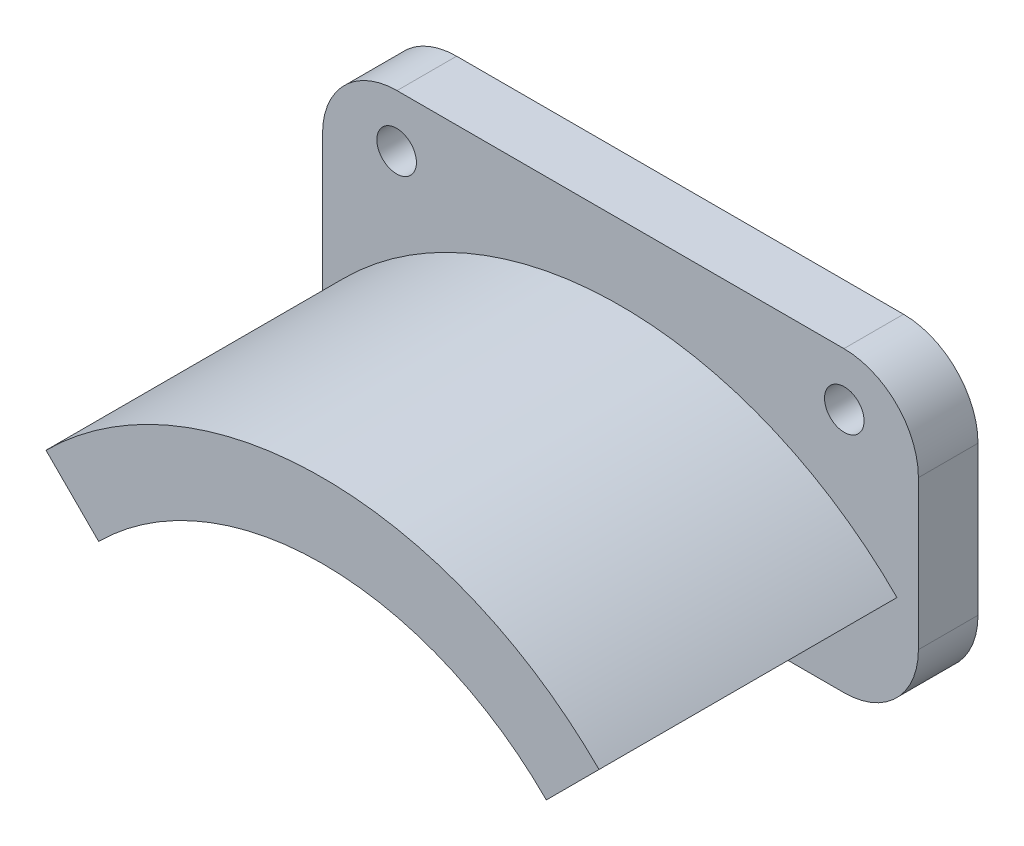
from build123d import *

# Parameters (mm, degrees)
BOSS_EXTRUDE1_DEPTH     = 20
SKETCH1_3_W             = 40
SKETCH1_3_H             = 20
BOSS_EXTRUDE2_DEPTH     = 4
FILLET1_R               = 5
CUT_EXTRUDE1_DEPTH      = 31
CUT_EXTRUDE1_DEPTH_BACK = 31
SKETCH2_R               = 1.327157312
SKETCH2_R_2             = 1.25


with BuildPart() as part:
    # Sketch1 → Boss-Extrude1 (new body)
    with BuildSketch(Plane.XY):
        with BuildLine():
            Line((15.0260191, -6.2239809), (18.561553006, -2.688446994))
            ThreePointArc((18.561553006, -2.688446994), (0, 5), (-18.561553006, -2.688446994))
            Line((-18.561553006, -2.688446994), (-15.0260191, -6.2239809))
            ThreePointArc((-15.0260191, -6.2239809), (0, 0), (15.0260191, -6.2239809))
        make_face()
    extrude(amount=BOSS_EXTRUDE1_DEPTH)


with BuildPart() as body_2:
    # Sketch1_3 → Boss-Extrude2 (new body)
    with BuildSketch(Plane.XY):
        Rectangle(SKETCH1_3_W, SKETCH1_3_H)
        with BuildLine():
            Line((18.561553006, -2.688446994), (15.0260191, -6.2239809))
            ThreePointArc((15.0260191, -6.2239809), (0, 0), (-15.0260191, -6.2239809))
            Line((-15.0260191, -6.2239809), (-18.561553006, -2.688446994))
            ThreePointArc((-18.561553006, -2.688446994), (0, 5), (18.561553006, -2.688446994))
        make_face(mode=Mode.SUBTRACT)
    extrude(amount=-BOSS_EXTRUDE2_DEPTH)

    # Fillet1
    fillet1_edges = [body_2.edges().sort_by_distance(p)[0] for p in [
        (20, 10, -2),
        (20, -10, -2),
        (-20, -10, -2),
        (-20, 10, -2),
    ]]
    fillet(fillet1_edges, radius=FILLET1_R)

    # Sketch2 → Cut-Extrude1 (cut, two sides: drawn at the far end of the back side and taken through both)
    with BuildSketch(Plane.XY.offset(-CUT_EXTRUDE1_DEPTH_BACK)):
        with Locations((15.024623413, 6.468859218)):
            Circle(SKETCH2_R)
        with Locations((0, -6.031140782)):
            Circle(SKETCH2_R_2)
        with Locations((-15.024623413, 6.468859218)):
            Circle(SKETCH2_R)
    extrude(amount=CUT_EXTRUDE1_DEPTH + CUT_EXTRUDE1_DEPTH_BACK, mode=Mode.SUBTRACT)


solid = Compound([part.part, body_2.part])
